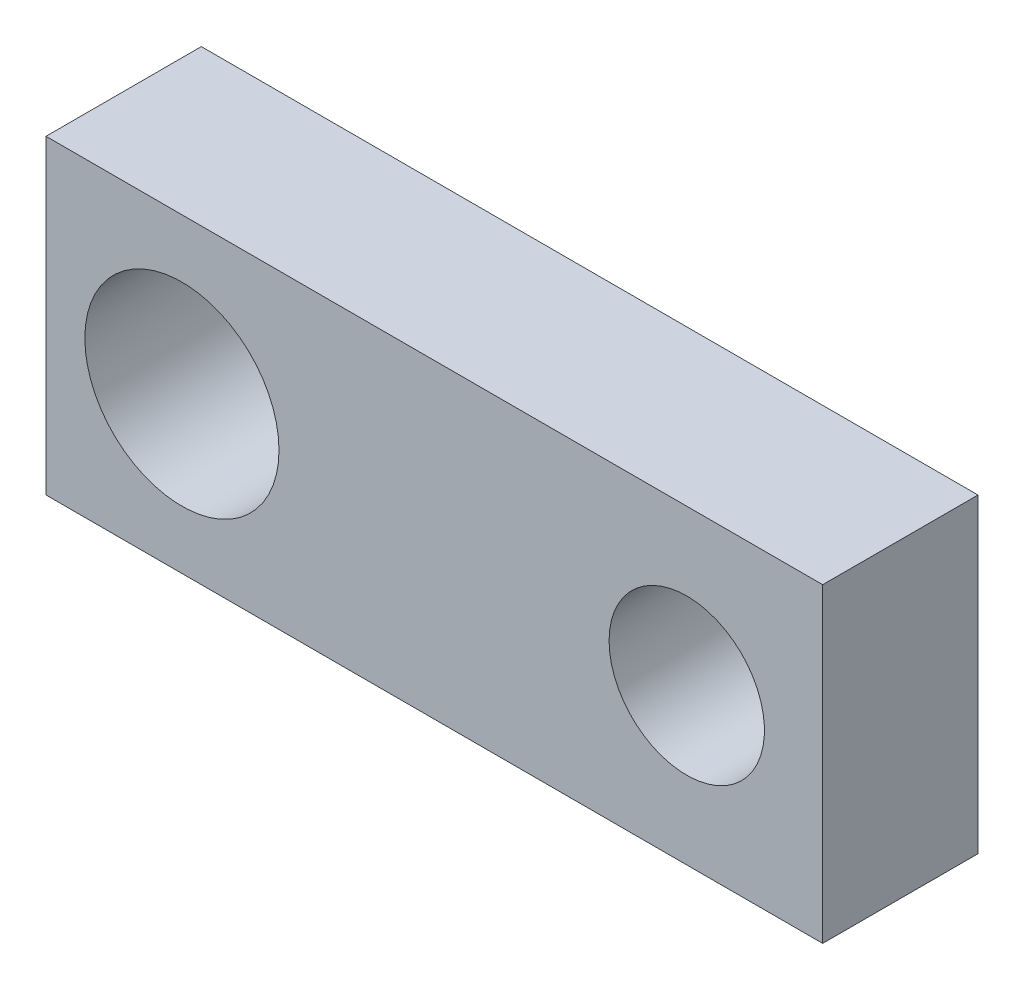
from build123d import *

# Parameters (mm, degrees)
ESQUISSE1_W      = 20
ESQUISSE1_H      = 8
ESQUISSE1_R      = 2.5
ESQUISSE1_R_2    = 2
EXTRUSION1_DEPTH = 4


with BuildPart() as part:
    # Esquisse1 → Extrusion1 (new body)
    with BuildSketch(Plane.XY):
        with Locations((10, 4)):
            Rectangle(ESQUISSE1_W, ESQUISSE1_H)
        with Locations((3.5, 4)):
            Circle(ESQUISSE1_R, mode=Mode.SUBTRACT)
        with Locations((16.5, 4)):
            Circle(ESQUISSE1_R_2, mode=Mode.SUBTRACT)
    extrude(amount=EXTRUSION1_DEPTH)


solid = part.part
